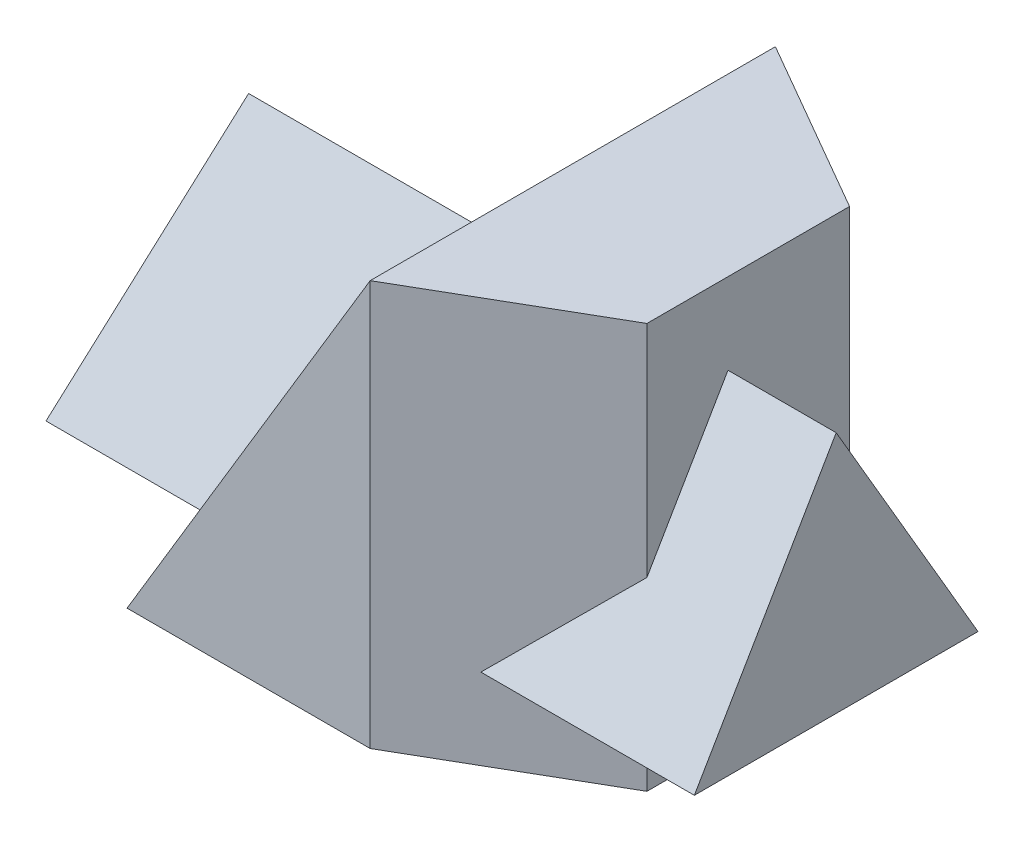
from build123d import *

# Parameters (mm, degrees)
EXTRUDE1_DEPTH = 100
EXTRUDE2_DEPTH = 101
EXTRUDE3_START = -30
EXTRUDE3_DEPTH = 160
EXTRUDE4_DEPTH = 160


with BuildPart() as part:
    # Sketch1 → Extrude1 (new body)
    with BuildSketch(Plane(origin=(0, 0, 0), x_dir=(1, 0, 0), z_dir=(0, 1, 0))):
        Polygon((60, 0), (103.301270189, 25), (103.301270189, 75), (60, 100), (0, 100), (0, 0), align=None)
    extrude(amount=EXTRUDE1_DEPTH)

    # Sketch2 → Extrude2 (cut, through all)
    with BuildSketch(Plane.XY):
        Polygon((60, 100), (0, 0), (0, 100), align=None)
    extrude(amount=-EXTRUDE2_DEPTH, mode=Mode.SUBTRACT)

    # Sketch3 → Extrude3 (add)
    with BuildSketch(Plane(origin=(0, 0, 0), x_dir=(0, 0, -1), z_dir=(1, 0, 0)).offset(EXTRUDE3_START)):
        Polygon((45, 80), (80, 20), (10, 20), align=None)
    extrude(amount=EXTRUDE3_DEPTH)

    # Sketch4 → Extrude4 (cut)
    with BuildSketch(Plane.XY):
        Polygon((-30, 20), (-15, 80), (-30, 80), align=None)
    extrude(amount=-EXTRUDE4_DEPTH, mode=Mode.SUBTRACT)


solid = part.part
